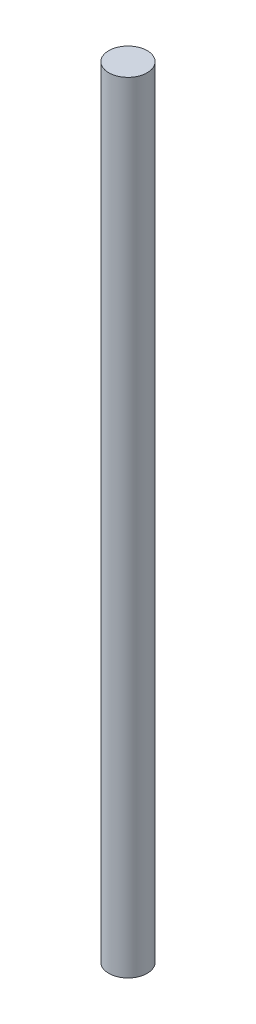
from build123d import *

# Parameters (mm, degrees)
SKETCH1_R           = 2.4511
BOSS_EXTRUDE1_DEPTH = 99.568


with BuildPart() as part:
    # Sketch1 → Boss-Extrude1 (new body)
    with BuildSketch(Plane(origin=(0, 0, 0), x_dir=(1, 0, 0), z_dir=(0, 1, 0))):
        with Locations(Location((0, 0, 0), (0, 0, 270))):  # turned: the seam where the file's is
            Circle(SKETCH1_R)
    extrude(amount=BOSS_EXTRUDE1_DEPTH)


solid = part.part
